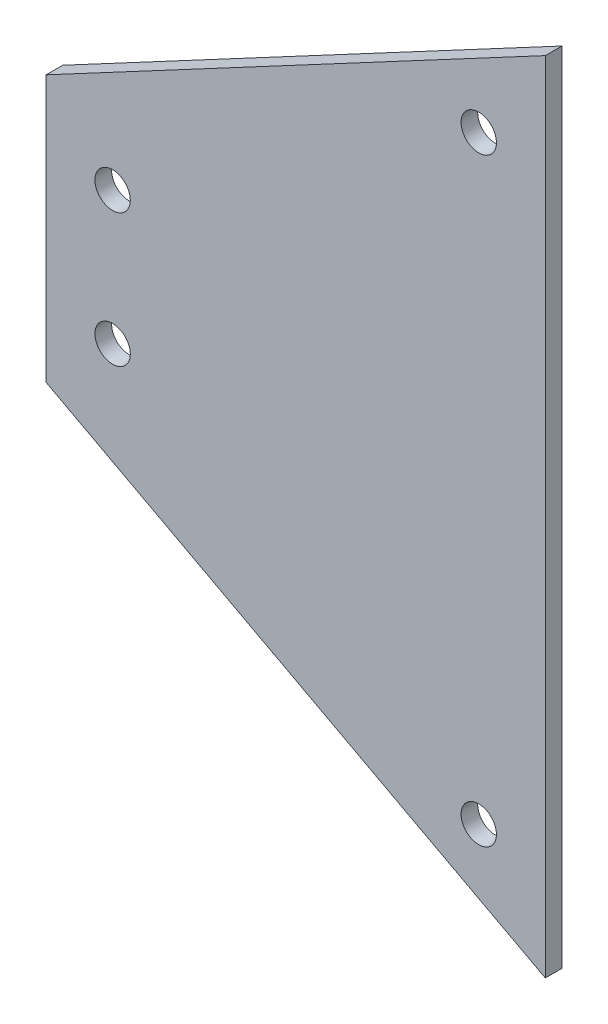
from build123d import *

# Parameters (mm, degrees)
BOSS_EXTRUDE3_DEPTH              = 1.5875
F_17_64_0_26563_DIAMETER_HOLE1_D = 6.747002


with BuildPart() as part:
    # Sketch2 → Boss-Extrude3 (new body, symmetric)
    with BuildSketch(Plane.XY):
        Polygon((-95.25, -25.4), (-95.25, 25.4), (0, 76.2), (0, -76.2), align=None)
    extrude(amount=BOSS_EXTRUDE3_DEPTH, both=True)

    # 17/64 (0.26563) Diameter Hole1 (through all)
    with Locations(Plane.XY.offset(1.5875)):
        with Locations((-82.55, 12.7), (-82.55, -12.7), (-12.7, -57.15), (-12.7, 57.15)):
            Hole(F_17_64_0_26563_DIAMETER_HOLE1_D / 2)


solid = part.part
